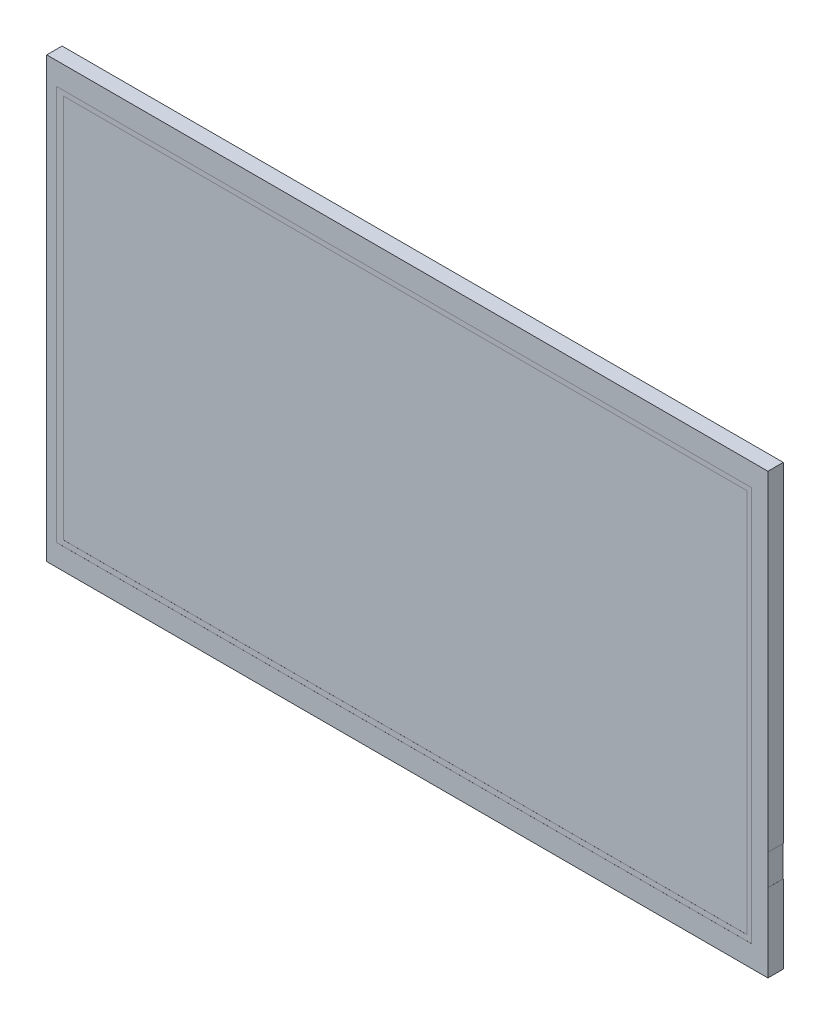
from build123d import *

# Parameters (mm, degrees)
SKETCH1_W           = 235
SKETCH1_H           = 143
BOSS_EXTRUDE1_DEPTH = 5
SKETCH2_W           = 226.4
SKETCH2_H           = 128.7
CUT_EXTRUDE1_DEPTH  = 0.01
SKETCH3_W           = 222.72
SKETCH3_H           = 125.28
CUT_EXTRUDE2_DEPTH  = 0.01
SKETCH4_W           = 5
SKETCH4_H           = 10
CUT_EXTRUDE3_DEPTH  = 0.01
SKETCH5_W           = 38.3
SKETCH5_H           = 2
CUT_EXTRUDE4_DEPTH  = 0.01


with BuildPart() as part:
    # Sketch1 → Boss-Extrude1 (new body)
    with BuildSketch(Plane.XY):
        Rectangle(SKETCH1_W, SKETCH1_H)
    extrude(amount=BOSS_EXTRUDE1_DEPTH)

    # Sketch2 → Cut-Extrude1 (cut)
    with BuildSketch(Plane.XY.offset(5)):
        with Locations((-1.05, -0.15)):
            Rectangle(SKETCH2_W, SKETCH2_H)
    extrude(amount=-CUT_EXTRUDE1_DEPTH, mode=Mode.SUBTRACT)

    # Sketch3 → Cut-Extrude2 (cut)
    with BuildSketch(Plane.XY.offset(4.99)):
        with Locations((-0.64, -0.05)):
            Rectangle(SKETCH3_W, SKETCH3_H)
    extrude(amount=-CUT_EXTRUDE2_DEPTH, mode=Mode.SUBTRACT)

    # Sketch4 → Cut-Extrude3 (cut)
    with BuildSketch(Plane(origin=(117.5, 0, 0), x_dir=(0, 0, -1), z_dir=(1, 0, 0))):
        with Locations((-2.5, -41)):
            Rectangle(SKETCH4_W, SKETCH4_H)
    extrude(amount=-CUT_EXTRUDE3_DEPTH, mode=Mode.SUBTRACT)

    # Sketch5 → Cut-Extrude4 (cut)
    with BuildSketch(Plane(origin=(0, -71.5, 0), x_dir=(-1, 0, 0), z_dir=(0, -1, 0))):
        with Locations((-5.83, -1)):
            Rectangle(SKETCH5_W, SKETCH5_H)
    extrude(amount=-CUT_EXTRUDE4_DEPTH, mode=Mode.SUBTRACT)


solid = part.part
